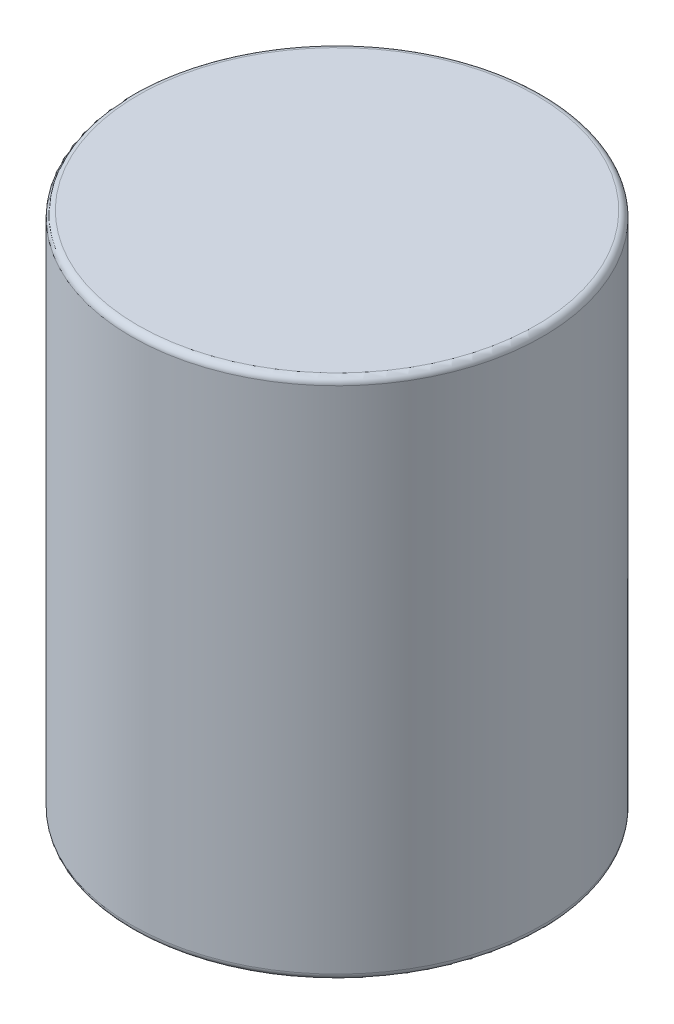
from build123d import *

# Parameters (mm, degrees)
SKETCH_1_R      = 3.15
EXTRUDE_1_DEPTH = 8
FILLET_1_R      = 0.1
FILLET_2_R      = 0.1


with BuildPart() as part:
    # Эскиз1 → Бобышка-Вытянуть1 (new body)
    with BuildSketch(Plane(origin=(0, 0, 0), x_dir=(1, 0, 0), z_dir=(0, 1, 0))):
        Circle(SKETCH_1_R)
    extrude(amount=EXTRUDE_1_DEPTH)

    # Скругление1
    fillet_1_edges = [part.edges().sort_by_distance(p)[0] for p in [
        (-3.15, 8, 0),
    ]]
    fillet(fillet_1_edges, radius=FILLET_1_R)

    # Скругление2
    fillet_2_edges = [part.edges().sort_by_distance(p)[0] for p in [
        (-3.15, 0, 0),
    ]]
    fillet(fillet_2_edges, radius=FILLET_2_R)


solid = part.part
